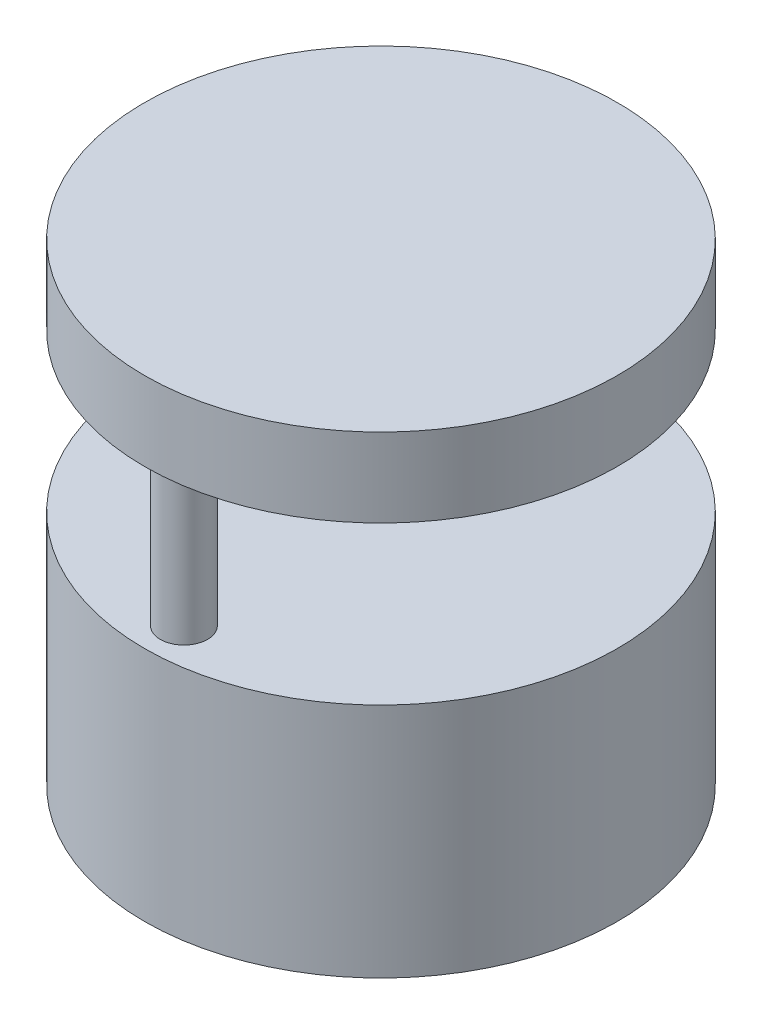
from build123d import *

# Parameters (mm, degrees)
SKETCH1_R           = 300
BOSS_EXTRUDE1_DEPTH = 300
SKETCH2_R           = 30
BOSS_EXTRUDE2_DEPTH = 200
SKETCH3_R           = 300
BOSS_EXTRUDE3_DEPTH = 100


with BuildPart() as part:
    # Sketch1 → Boss-Extrude1 (new body)
    with BuildSketch(Plane(origin=(0, 0, 0), x_dir=(1, 0, 0), z_dir=(0, 1, 0))):
        Circle(SKETCH1_R)
    extrude(amount=BOSS_EXTRUDE1_DEPTH)

    # Sketch2 → Boss-Extrude2 (add)
    with BuildSketch(Plane(origin=(0, 300, 0), x_dir=(1, 0, 0), z_dir=(0, 1, 0))):
        with Locations((0, 250)):
            Circle(SKETCH2_R)
        with Locations((0, -250)):
            Circle(SKETCH2_R)
    extrude(amount=BOSS_EXTRUDE2_DEPTH)

    # Sketch3 → Boss-Extrude3 (add)
    with BuildSketch(Plane(origin=(0, 500, 0), x_dir=(1, 0, 0), z_dir=(0, 1, 0))):
        Circle(SKETCH3_R)
    extrude(amount=BOSS_EXTRUDE3_DEPTH)


solid = part.part
